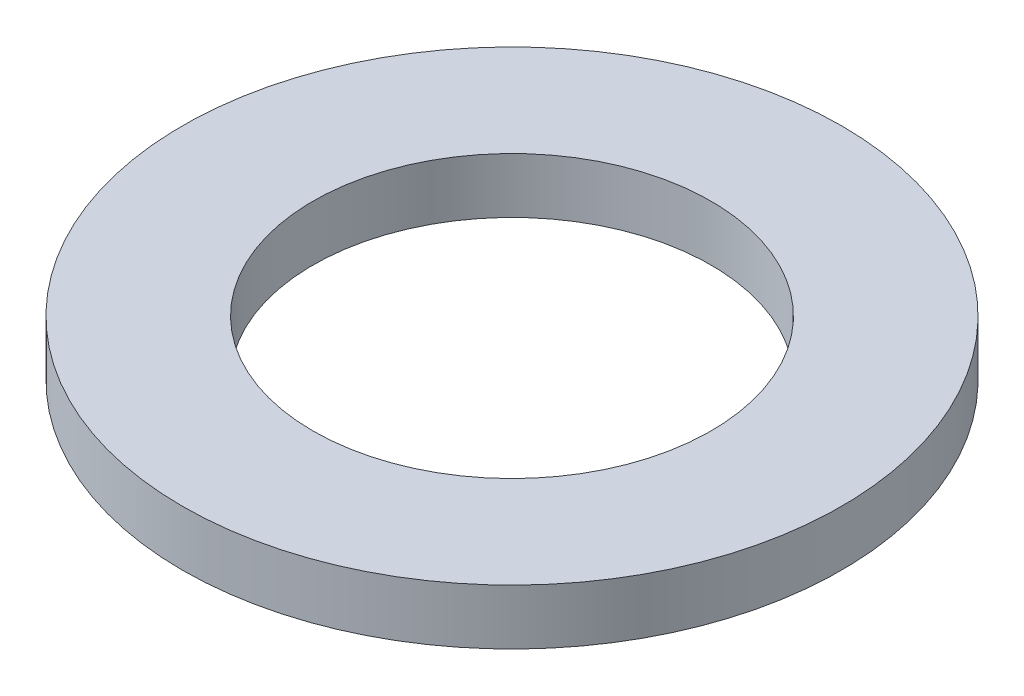
from build123d import *

# Parameters (mm, degrees)
SKETCH2_R          = 9.525
SKETCH2_R_2        = 5.7531
BASE_EXTRUDE_DEPTH = 1.6002


with BuildPart() as part:
    # Sketch2 → Base-Extrude (new body)
    with BuildSketch(Plane(origin=(0, 0, 0), x_dir=(1, 0, 0), z_dir=(0, 1, 0))):
        Circle(SKETCH2_R)
        Circle(SKETCH2_R_2, mode=Mode.SUBTRACT)
    extrude(amount=BASE_EXTRUDE_DEPTH)


solid = part.part
